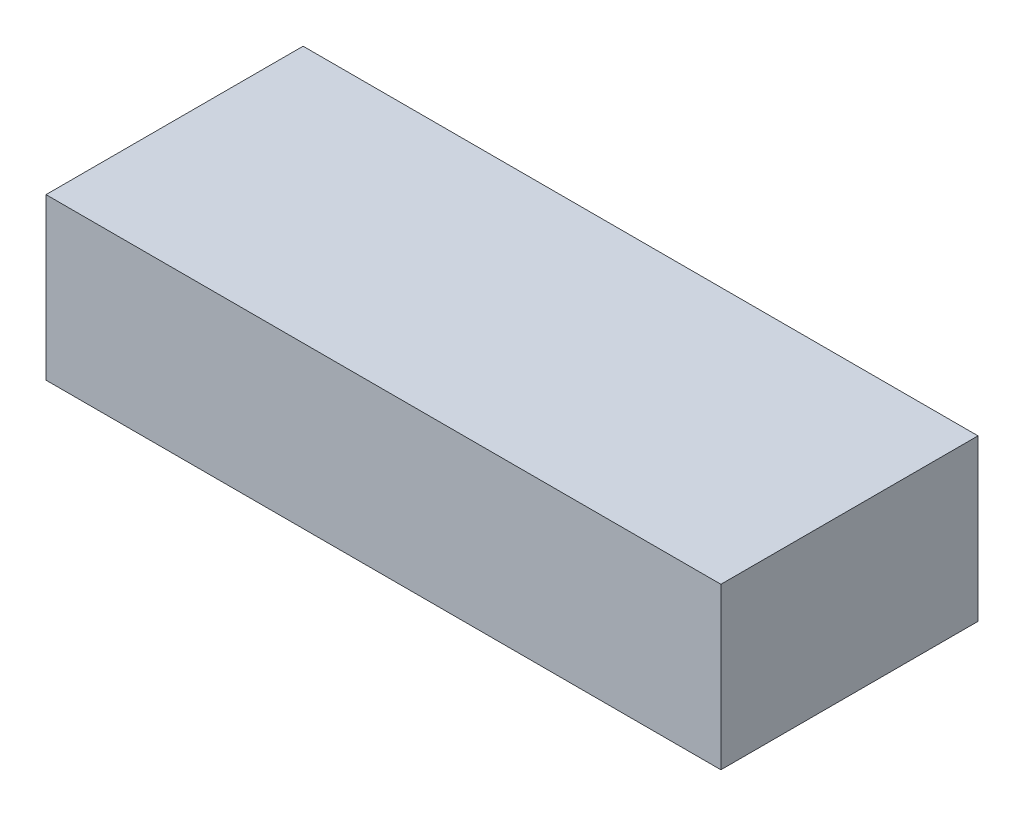
from build123d import *

# Parameters (mm, degrees)
SKETCH1_W           = 66.675
SKETCH1_H           = 25.4
BOSS_EXTRUDE1_DEPTH = 15.875


with BuildPart() as part:
    # Sketch1 → Boss-Extrude1 (new body)
    with BuildSketch(Plane(origin=(0, 0, 0), x_dir=(1, 0, 0), z_dir=(0, 1, 0))):
        with Locations((33.3375, 12.7)):
            Rectangle(SKETCH1_W, SKETCH1_H)
    extrude(amount=BOSS_EXTRUDE1_DEPTH)


solid = part.part
